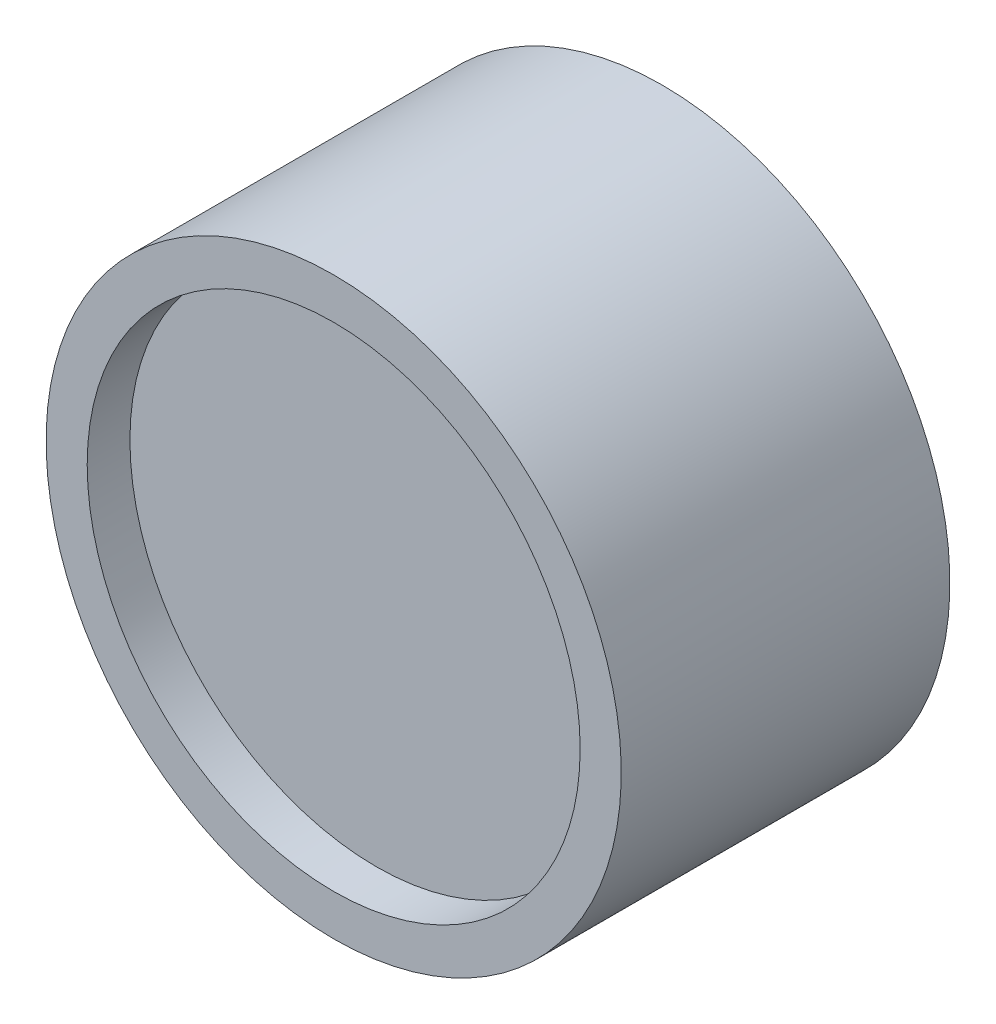
from build123d import *

# Parameters (mm, degrees)
F_1_8_0_125_DIAMETER_HOLE1_D     = 3.175
F_1_8_0_125_DIAMETER_HOLE1_DEPTH = 15.875
F_1_8_0_125_DIAMETER_HOLE1_TIP   = 0.953866233


with BuildPart() as part:
    # Sketch1 → Revolve1 (revolve)
    with BuildSketch(Plane(origin=(0, 0, 0), x_dir=(0, 0, -1), z_dir=(1, 0, 0))):
        Polygon((0, 0), (-9.398, 0), (-9.398, 19.05), (-12.7, 19.05), (-12.7, 22.225), (12.7, 22.225), (12.7, 19.05), (9.398, 19.05), (9.398, 0), align=None)
    revolve(axis=Axis((0, 0, 0), (0, 0, 1)))

    # 1/8 (0.125) Diameter Hole1
    with Locations(Plane(origin=(0, -22.225, 0), x_dir=(-1, 0, 0), z_dir=(0, -1, 0))):
        with Locations((0, 0)):
            Hole(F_1_8_0_125_DIAMETER_HOLE1_D / 2, depth=F_1_8_0_125_DIAMETER_HOLE1_DEPTH)
            with Locations((0, 0, -(F_1_8_0_125_DIAMETER_HOLE1_DEPTH + F_1_8_0_125_DIAMETER_HOLE1_TIP / 2))):  # 118° drill point
                Cone(0, F_1_8_0_125_DIAMETER_HOLE1_D / 2, F_1_8_0_125_DIAMETER_HOLE1_TIP, mode=Mode.SUBTRACT)


solid = part.part
